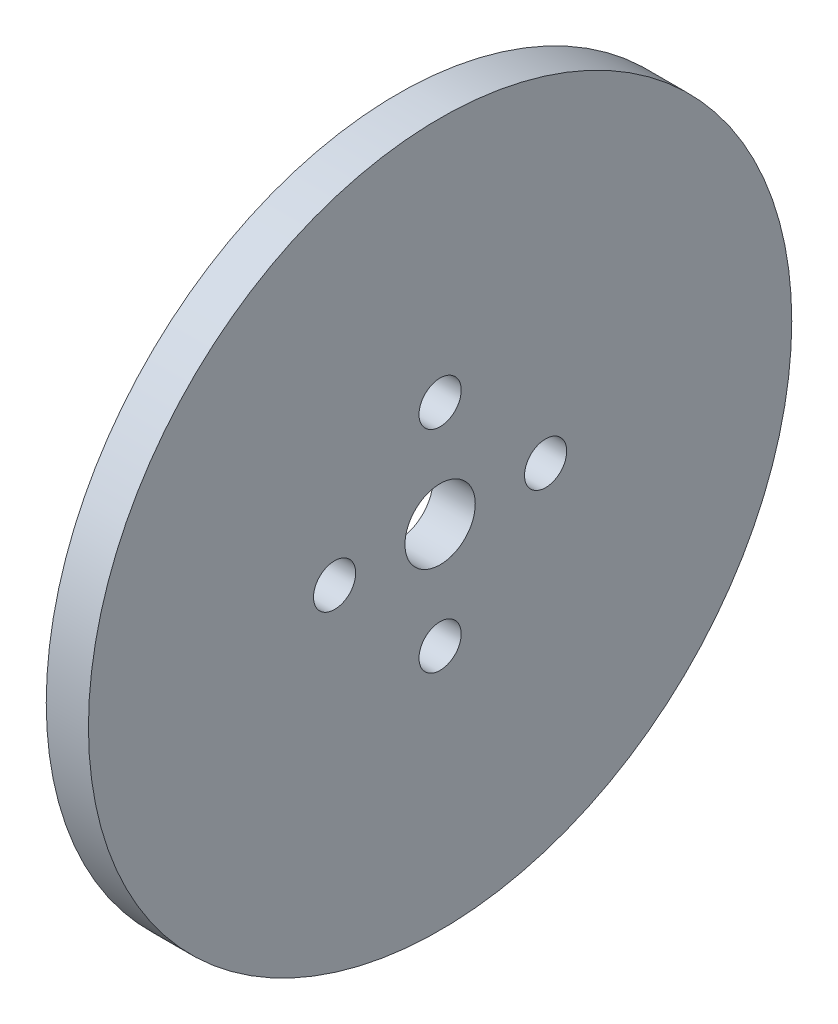
from build123d import *

# Parameters (mm, degrees)
CROQUIS1_R              = 25
CROQUIS1_R_2            = 2.5
CROQUIS1_R_3            = 1.5
SALIENTE_EXTRUIR1_DEPTH = 3


with BuildPart() as part:
    # Croquis1 → Saliente-Extruir1 (new body)
    with BuildSketch(Plane(origin=(0, 0, 0), x_dir=(0, 0, -1), z_dir=(1, 0, 0))):
        Circle(CROQUIS1_R)
        Circle(CROQUIS1_R_2, mode=Mode.SUBTRACT)
        with Locations((0, 7.5)):
            Circle(CROQUIS1_R_3, mode=Mode.SUBTRACT)
        with Locations((7.5, 0)):
            Circle(CROQUIS1_R_3, mode=Mode.SUBTRACT)
        with Locations((0, -7.5)):
            Circle(CROQUIS1_R_3, mode=Mode.SUBTRACT)
        with Locations((-7.5, 0)):
            Circle(CROQUIS1_R_3, mode=Mode.SUBTRACT)
    extrude(amount=SALIENTE_EXTRUIR1_DEPTH)


solid = part.part
